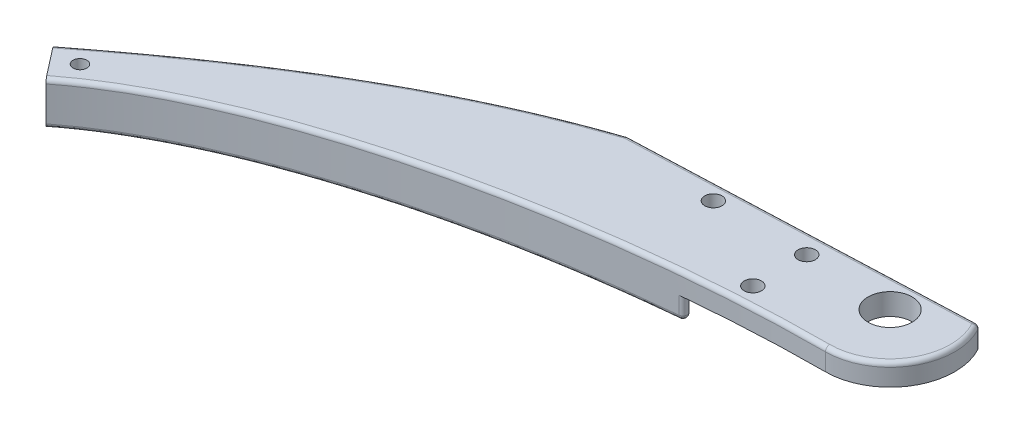
from build123d import *

# Parameters (mm, degrees)
SKETCH1_R           = 1.600000009
BOSS_EXTRUDE4_DEPTH = 10
SKETCH2_R           = 15
SKETCH2_R_2         = 5
SKETCH2_R_3         = 1.5
BOSS_EXTRUDE6_DEPTH = 5
CUT_EXTRUDE2_DEPTH  = 5
CUT_EXTRUDE4_DEPTH  = 5
SKETCH7_R           = 5.1
CUT_EXTRUDE3_DEPTH  = 10
FILLET8_R           = 1
SKETCH11_R          = 2
CUT_EXTRUDE5_DEPTH  = 6.0000001


with BuildPart() as part:
    # Sketch1 → Boss-Extrude4 (new body)
    with BuildSketch(Plane(origin=(0, 0, 0), x_dir=(1, 0, 0), z_dir=(0, 1, 0))):
        with BuildLine():
            add(Edge.make_bspline(
                [(0, 15), (-53.333333333, 15), (-97.583219031, -2.850331237), (-150.232513568, -43.746495229)],
                knots=[0, 0, 0, 0, 1, 1, 1, 1], degree=3))
            Line((-150.232513568, -43.746495229), (-144.167390422, -51.554671443))
            add(Edge.make_bspline(
                [(0, -15), (-49.211171547, -15), (-112.5778137, -27.016973048), (-144.167390422, -51.554671443)],
                knots=[0, 0, 0, 0, 1, 1, 1, 1], degree=3))
            ThreePointArc((0, -15), (15, 0), (0, 15))
        make_face()
        with Locations((-143.201137436, -44.647891744)):
            Circle(SKETCH1_R, mode=Mode.SUBTRACT)
    extrude(amount=BOSS_EXTRUDE4_DEPTH)

    # Sketch2 → Boss-Extrude6 (add)
    with BuildSketch(Plane.XZ):
        Circle(SKETCH2_R)
        with Locations((16.383040886, -11.471528727)):
            Circle(SKETCH2_R_2)
        with Locations((16.383040886, -11.471528727)):
            Circle(SKETCH2_R_3, mode=Mode.SUBTRACT)
    extrude(amount=-BOSS_EXTRUDE6_DEPTH)

    # Sketch6 → Cut-Extrude2 (cut)
    with BuildSketch(Plane(origin=(0, 10, 0), x_dir=(1, 0, 0), z_dir=(0, 1, 0))):
        Polygon((-65.408961084, 4.598984297), (12.891910286, 7.668027724), (7.272272722, 26.292385098), (-49.302567283, 23.06136309), align=None)
    extrude(amount=-CUT_EXTRUDE2_DEPTH, mode=Mode.SUBTRACT)

    # Sketch9 → Cut-Extrude4 (cut)
    with BuildSketch(Plane.XZ):
        Polygon((-29.210981827, 16.299928772), (-65.408961084, -4.598984297), (-53.167537272, -38.219205759), (79.787707686, -46.822420026), (23.799304787, 49.274642551), align=None)
    extrude(amount=-CUT_EXTRUDE4_DEPTH, mode=Mode.SUBTRACT)

    # Sketch7 → Cut-Extrude3 (cut)
    with BuildSketch(Plane(origin=(0, 10, 0), x_dir=(1, 0, 0), z_dir=(0, 1, 0))):
        Circle(SKETCH7_R)
    extrude(amount=-CUT_EXTRUDE3_DEPTH, mode=Mode.SUBTRACT)

    # Fillet8
    fillet8_edges = [part.edges().sort_by_distance(p)[0] for p in [
        (-74.858183183, 10, 23.204180957),
        (13.038796261, 10, 7.415510237),
        (-109.827962706, 10, 15.996913206),
        (-26.258525399, 10, -6.13350601),
        (12.891910286, 7.5, -7.668027724),
        (-109.827962706, 0, 15.996913206),
        (-89.056948964, 0, 26.700662707),
        (-47.309971455, 0, 5.850472238),
        (-29.210981827, 2.5, 16.299928772),
    ]]
    fillet(fillet8_edges, radius=FILLET8_R)

    # Sketch11 → Cut-Extrude5 (cut, through all)
    with BuildSketch(Plane.XZ.offset(-5)):
        with Locations((-20.67601836, 11.156706002)):
            Circle(SKETCH11_R)
        with Locations((-20.67601836, -1.343293998)):
            Circle(SKETCH11_R)
        with Locations((-42.326653454, -1.343293998)):
            Circle(SKETCH11_R)
    extrude(amount=-CUT_EXTRUDE5_DEPTH, mode=Mode.SUBTRACT)


solid = part.part
